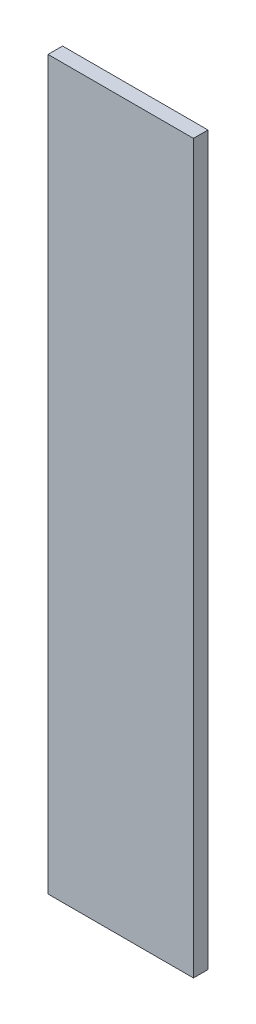
from build123d import *

# Parameters (mm, degrees)
SKETCH1_W           = 200
SKETCH1_H           = 1000
BOSS_EXTRUDE1_DEPTH = 20


with BuildPart() as part:
    # Sketch1 → Boss-Extrude1 (new body)
    with BuildSketch(Plane.XY):
        with Locations((100, 500)):
            Rectangle(SKETCH1_W, SKETCH1_H)
    extrude(amount=BOSS_EXTRUDE1_DEPTH)


solid = part.part
